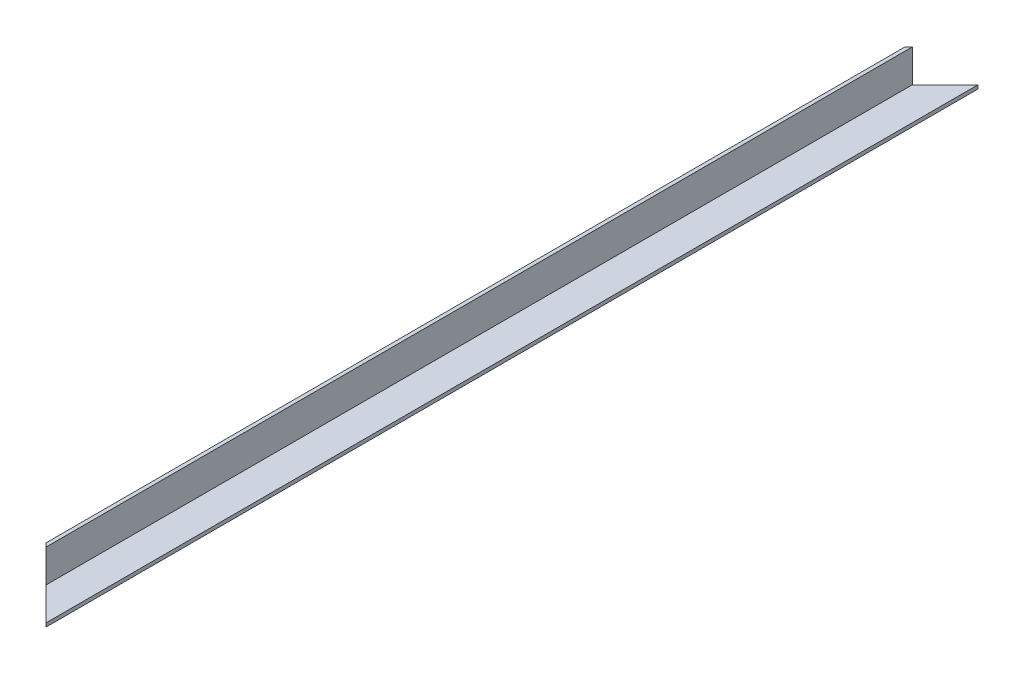
from build123d import *

# Parameters (mm, degrees)
BOSS_EXTRUDE1_DEPTH = 511
CUT_EXTRUDE1_DEPTH  = 23


with BuildPart() as part:
    # Sketch1 → Boss-Extrude1 (new body)
    with BuildSketch(Plane.XY):
        Polygon((0, 0), (20, 0), (20, 2), (2, 2), (2, 20), (0, 20), align=None)
    extrude(amount=BOSS_EXTRUDE1_DEPTH)

    # Sketch2 → Cut-Extrude1 (cut, symmetric)
    with BuildSketch(Plane(origin=(0, 2, 0), x_dir=(1, 0, 0), z_dir=(0, 1, 0))):
        Polygon((0, -511), (20, -511), (0, -491), align=None)
        Polygon((20, 0), (0, -20), (0, 0), align=None)
    extrude(amount=CUT_EXTRUDE1_DEPTH, both=True, mode=Mode.SUBTRACT)


solid = part.part
